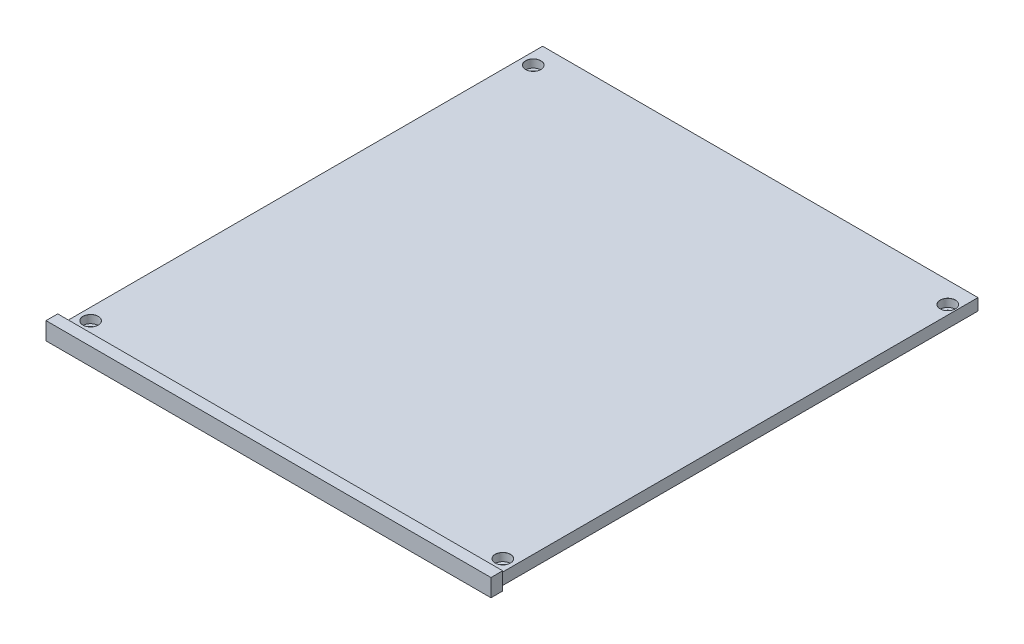
from build123d import *

# Parameters (mm, degrees)
SKETCH1_W                                      = 190
SKETCH1_H                                      = 10
BOSS_EXTRUDE1_DEPTH                            = 5
SKETCH2_W                                      = 185.9
SKETCH2_H                                      = 4.99
BOSS_EXTRUDE2_DEPTH                            = 205
CBORE_FOR_M3_SOCKET_HEAD_CAP_SCREW1_AT_2_COUNT = 2
CBORE_FOR_M3_SOCKET_HEAD_CAP_SCREW1_AT_2_PITCH = 176
CBORE_FOR_M3_SOCKET_HEAD_CAP_SCREW1_AT_3_COUNT = 2
CBORE_FOR_M3_SOCKET_HEAD_CAP_SCREW1_AT_3_PITCH = 258.940147524
CBORE_FOR_M3_SOCKET_HEAD_CAP_SCREW1_AT_4_COUNT = 2
CBORE_FOR_M3_SOCKET_HEAD_CAP_SCREW1_AT_4_PITCH = 189
SKETCH6_W                                      = 190
SKETCH6_H                                      = 22.149014811
CUT_EXTRUDE1_DEPTH                             = 10


with BuildPart() as part:
    # Sketch1 → Boss-Extrude1 (new body)
    with BuildSketch(Plane.XY):
        Rectangle(SKETCH1_W, SKETCH1_H)
    extrude(amount=BOSS_EXTRUDE1_DEPTH)

    # Sketch2 → Boss-Extrude2 (add)
    with BuildSketch(Plane(origin=(0, 0, 0), x_dir=(-1, 0, 0), z_dir=(0, 0, -1))):
        Rectangle(SKETCH2_W, SKETCH2_H)
    extrude(amount=BOSS_EXTRUDE2_DEPTH)

    # Sketch5 → CBORE for M3 Socket Head Cap Screw1 (revolve, cut)
    with BuildSketch(Plane(origin=(-87.95, 2.495, -7), x_dir=(0, 0, 1), z_dir=(1, 0, 0))):
        Polygon((0, 0), (0, 21.081549114), (1.8, 20), (1.8, 3.4), (3.25, 3.4), (3.25, 0.025), (3.275, 0), align=None)
    cbore_for_m3_socket_head_cap_screw1 = revolve(axis=Axis((-87.95, 8.845, -7), (0, -1, 0)), mode=Mode.SUBTRACT)

    # CBORE for M3 Socket Head Cap Screw1 at 2: CBORE for M3 Socket Head Cap Screw1 ×2
    with Locations(*[(i * CBORE_FOR_M3_SOCKET_HEAD_CAP_SCREW1_AT_2_PITCH, 0, 0) for i in range(1, CBORE_FOR_M3_SOCKET_HEAD_CAP_SCREW1_AT_2_COUNT)]):
        add(cbore_for_m3_socket_head_cap_screw1, mode=Mode.SUBTRACT)

    # CBORE for M3 Socket Head Cap Screw1 at 3: CBORE for M3 Socket Head Cap Screw1 ×2
    with Locations(*[Vector(0.683555647, 0, -0.729898402) * (i * CBORE_FOR_M3_SOCKET_HEAD_CAP_SCREW1_AT_3_PITCH) for i in range(1, CBORE_FOR_M3_SOCKET_HEAD_CAP_SCREW1_AT_3_COUNT)]):
        add(cbore_for_m3_socket_head_cap_screw1, mode=Mode.SUBTRACT)

    # CBORE for M3 Socket Head Cap Screw1 at 4: CBORE for M3 Socket Head Cap Screw1 ×2
    with Locations(*[(0, 0, -i * CBORE_FOR_M3_SOCKET_HEAD_CAP_SCREW1_AT_4_PITCH) for i in range(1, CBORE_FOR_M3_SOCKET_HEAD_CAP_SCREW1_AT_4_COUNT)]):
        add(cbore_for_m3_socket_head_cap_screw1, mode=Mode.SUBTRACT)

    # Sketch6 → Cut-Extrude1 (cut)
    with BuildSketch(Plane(origin=(0, 0, 0), x_dir=(-1, 0, 0), z_dir=(0, 0, -1))):
        with Locations((0, -13.569507406)):
            Rectangle(SKETCH6_W, SKETCH6_H)
    extrude(amount=-CUT_EXTRUDE1_DEPTH, mode=Mode.SUBTRACT)


solid = part.part
